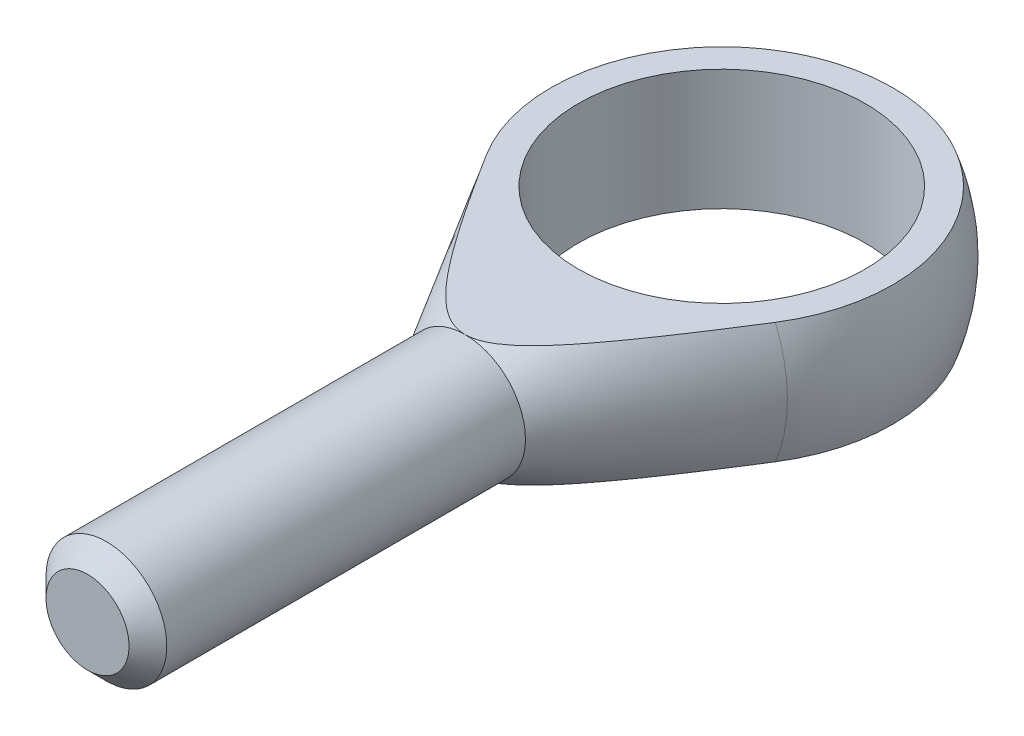
from build123d import *

# Parameters (mm, degrees)
SZKIC1_W                        = 4
SZKIC1_H                        = 25
WYTNIJ_WYCI_GNI_CIE1_DEPTH      = 13
WYTNIJ_WYCI_GNI_CIE1_DEPTH_BACK = 13
SZKIC3_R                        = 9.5
WYTNIJ_WYCI_GNI_CIE2_DEPTH      = 5
WYTNIJ_WYCI_GNI_CIE2_DEPTH_BACK = 5
SFAZOWANIE1_SIZE                = 1.25


with BuildPart() as part:
    # Szkic1 → Obrót1 (revolve)
    with BuildSketch(Plane(origin=(0, 0, 0), x_dir=(1, 0, 0), z_dir=(0, 1, 0))):
        with BuildLine():
            Line((0, 12), (0, -17))
            Line((0, -17), (4, -17))
            Line((4, -17), (10.37531088, -6.029338617))
            ThreePointArc((10.37531088, -6.029338617), (10.400770726, 5.985312715), (0, 12))
        make_face()
        with Locations((2, -29.5)):
            Rectangle(SZKIC1_W, SZKIC1_H)
    revolve(axis=Axis((0, 0, -26.043516498), (0, 0, 1)))

    # Szkic2 → Wytnij-wyciągnięcie1 (cut, two sides)
    with BuildSketch(Plane(origin=(0, 0, 0), x_dir=(0, 0, -1), z_dir=(1, 0, 0))) as wytnij_wyci_gni_cie1_sk:
        with BuildLine():
            Line((-17, 4), (11.313708499, 4))
            ThreePointArc((11.313708499, 4), (4.140324681, 11.263112871), (-6.029338617, 10.37531088))
            Line((-6.029338617, 10.37531088), (-17, 4))
        make_face()
        with BuildLine():
            Line((-17, -4), (11.313708499, -4))
            ThreePointArc((11.313708499, -4), (4.140324681, -11.263112871), (-6.029338617, -10.37531088))
            Line((-6.029338617, -10.37531088), (-17, -4))
        make_face()
    extrude(amount=WYTNIJ_WYCI_GNI_CIE1_DEPTH, mode=Mode.SUBTRACT)
    extrude(wytnij_wyci_gni_cie1_sk.sketch, amount=-WYTNIJ_WYCI_GNI_CIE1_DEPTH_BACK, mode=Mode.SUBTRACT)

    # Szkic3 → Wytnij-wyciągnięcie2 (cut, two sides)
    with BuildSketch(Plane(origin=(0, 0, 0), x_dir=(1, 0, 0), z_dir=(0, 1, 0))) as wytnij_wyci_gni_cie2_sk:
        Circle(SZKIC3_R)
    extrude(amount=WYTNIJ_WYCI_GNI_CIE2_DEPTH, mode=Mode.SUBTRACT)
    extrude(wytnij_wyci_gni_cie2_sk.sketch, amount=-WYTNIJ_WYCI_GNI_CIE2_DEPTH_BACK, mode=Mode.SUBTRACT)

    # Sfazowanie1
    sfazowanie1_edges = [part.edges().sort_by_distance(p)[0] for p in [
        (-4, 0, 42),
    ]]
    chamfer(sfazowanie1_edges, length=SFAZOWANIE1_SIZE)


solid = part.part
